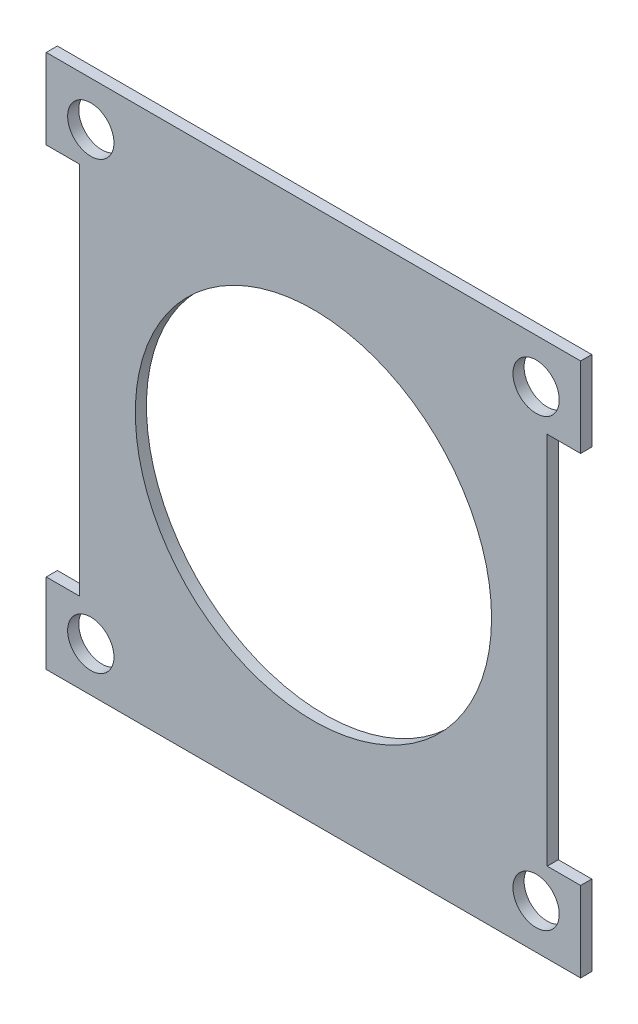
from build123d import *

# Parameters (mm, degrees)
SKETCH1_W               = 76.2
SKETCH1_H               = 76.2
SKETCH1_R               = 25.4
BOSS_EXTRUDE1_DEPTH     = 1.5875
SKETCH2_R               = 3.302
CUT_EXTRUDE1_DEPTH      = 3.175
MIRROR2_COPY_1_SKETCH_R = 3.302
MIRROR2_COPY_1_DEPTH    = 3.175
MIRROR2_COPY_2_SKETCH_R = 3.302
MIRROR2_COPY_2_DEPTH    = 3.175
SKETCH9_W               = 4.7625
SKETCH9_H               = 53.34
CUT_EXTRUDE3_DEPTH      = 54.904917737


with BuildPart() as part:
    # Sketch1 → Boss-Extrude1 (new body)
    with BuildSketch(Plane.XY):
        Rectangle(SKETCH1_W, SKETCH1_H)
        Circle(SKETCH1_R, mode=Mode.SUBTRACT)
    extrude(amount=BOSS_EXTRUDE1_DEPTH)

    # Sketch2 → Cut-Extrude1 (cut)
    with BuildSketch(Plane.XY.offset(1.5875)):
        with Locations((-31.75, 31.75)):
            Circle(SKETCH2_R)
    cut_extrude1 = extrude(amount=-CUT_EXTRUDE1_DEPTH, mode=Mode.SUBTRACT)

    # Mirror1: Cut-Extrude1 across plane
    add(cut_extrude1.mirror(Plane(origin=(0, 0, 0), x_dir=(0, 0, 1), z_dir=(1, 0, 0))), mode=Mode.SUBTRACT)

    # Mirror2 copy 1 sketch → Mirror2 copy 1 (cut)
    with BuildSketch(Plane(origin=(0, 0, 1.5875), x_dir=(-1, 0, 0), z_dir=(0, 0, 1))):
        with Locations((-31.75, 31.75)):
            Circle(MIRROR2_COPY_1_SKETCH_R)
    extrude(amount=-MIRROR2_COPY_1_DEPTH, mode=Mode.SUBTRACT)

    # Mirror2 copy 2 sketch → Mirror2 copy 2 (cut)
    with BuildSketch(Plane.XY.offset(1.5875)):
        with Locations((-31.75, -31.75)):
            Circle(MIRROR2_COPY_2_SKETCH_R)
    extrude(amount=-MIRROR2_COPY_2_DEPTH, mode=Mode.SUBTRACT)

    # Sketch9 → Cut-Extrude3 (cut, through all)
    with BuildSketch(Plane.XY.offset(1.5875)):
        with Locations((-35.71875, 0)):
            Rectangle(SKETCH9_W, SKETCH9_H)
    cut_extrude3 = extrude(amount=-CUT_EXTRUDE3_DEPTH, mode=Mode.SUBTRACT)

    # Mirror3: Cut-Extrude3 across plane
    add(cut_extrude3.mirror(Plane(origin=(0, 0, 0), x_dir=(0, 0, 1), z_dir=(1, 0, 0))), mode=Mode.SUBTRACT)


solid = part.part
